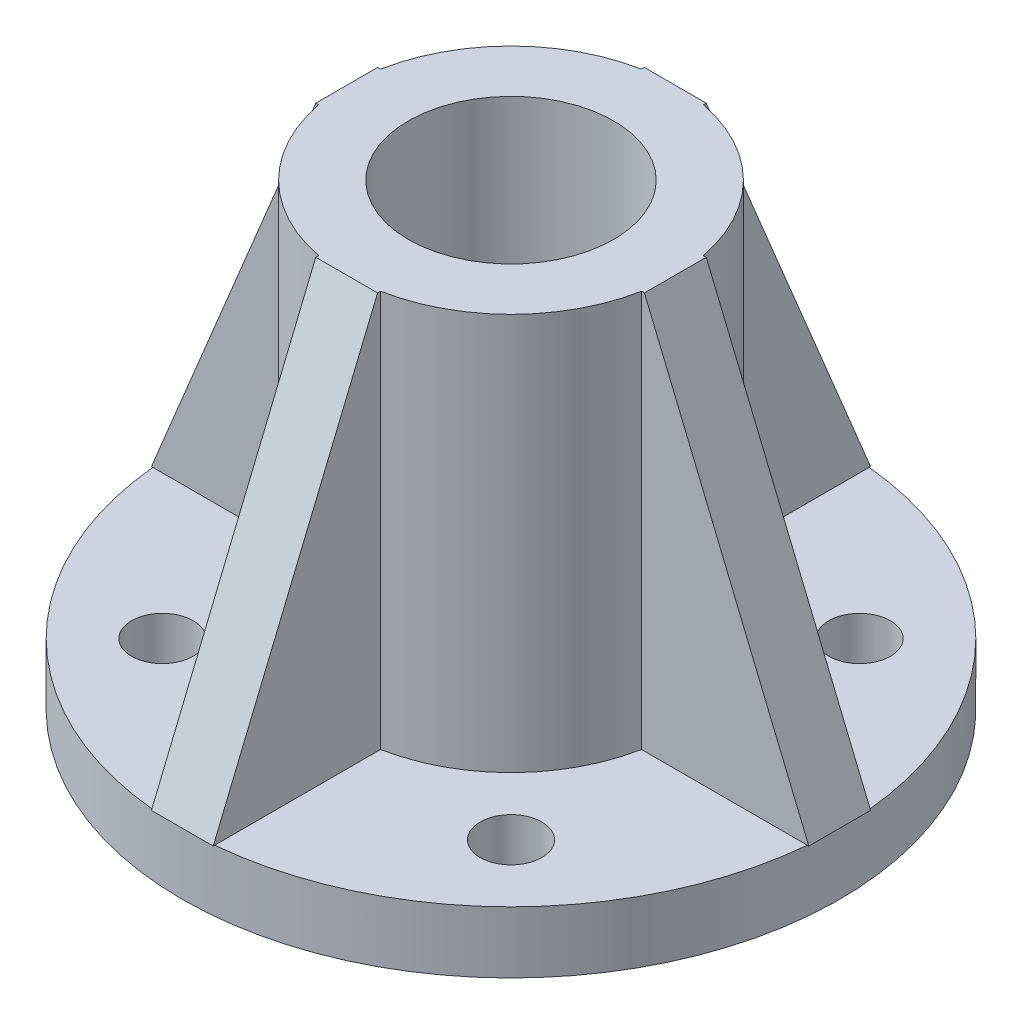
from build123d import *

# Parameters (mm, degrees)
SKETCH1_R           = 50.8
SKETCH1_R_2         = 15.875
BOSS_EXTRUDE1_DEPTH = 9.525
SKETCH4_R           = 25.4
SKETCH4_R_2         = 15.875
BOSS_EXTRUDE2_DEPTH = 61.341
BOSS_EXTRUDE3_DEPTH = 4.7752
CIRPATTERN1_COUNT   = 4


with BuildPart() as part:
    # Sketch1 → Boss-Extrude1 (new body)
    with BuildSketch(Plane(origin=(0, 0, 0), x_dir=(1, 0, 0), z_dir=(0, 1, 0))):
        Circle(SKETCH1_R)
        Circle(SKETCH1_R_2, mode=Mode.SUBTRACT)
    extrude(amount=BOSS_EXTRUDE1_DEPTH)

    # Sketch4 → Boss-Extrude2 (add)
    with BuildSketch(Plane(origin=(0, 9.525, 0), x_dir=(1, 0, 0), z_dir=(0, 1, 0))):
        Circle(SKETCH4_R)
        Circle(SKETCH4_R_2, mode=Mode.SUBTRACT)
    extrude(amount=BOSS_EXTRUDE2_DEPTH)

    # Sketch7 → Boss-Extrude3 (add, symmetric)
    with BuildSketch(Plane.XY):
        Polygon((-25.4, 70.866), (-50.8, 9.525), (-22.583366139, 9.525), (-22.583366139, 70.866), align=None)
    boss_extrude3 = extrude(amount=BOSS_EXTRUDE3_DEPTH, both=True)

    # Sketch9 → 1_4 _0.375_ Diameter Hole1 (revolve, cut)
    with BuildSketch(Plane(origin=(-26.940768363, 9.525, 26.940768363), x_dir=(0, 0, 1), z_dir=(1, 0, 0))):
        Polygon((0, 0), (0, 21.911598698), (4.7625, 19.05), (4.7625, 0), align=None)
    f_1_4_0_375_diameter_hole1 = revolve(axis=Axis((-26.940768363, 15.875, 26.940768363), (0, -1, 0)), mode=Mode.SUBTRACT)

    # CirPattern1: Boss-Extrude3, 1_4 _0.375_ Diameter Hole1 ×4 about axis
    cirpattern1_axis = Axis((0, 0, 0), (0, 1, 0))
    for i in range(1, CIRPATTERN1_COUNT):
        add(boss_extrude3.rotate(cirpattern1_axis, i * 360 / CIRPATTERN1_COUNT))
        add(f_1_4_0_375_diameter_hole1.rotate(cirpattern1_axis, i * 360 / CIRPATTERN1_COUNT), mode=Mode.SUBTRACT)


solid = part.part
